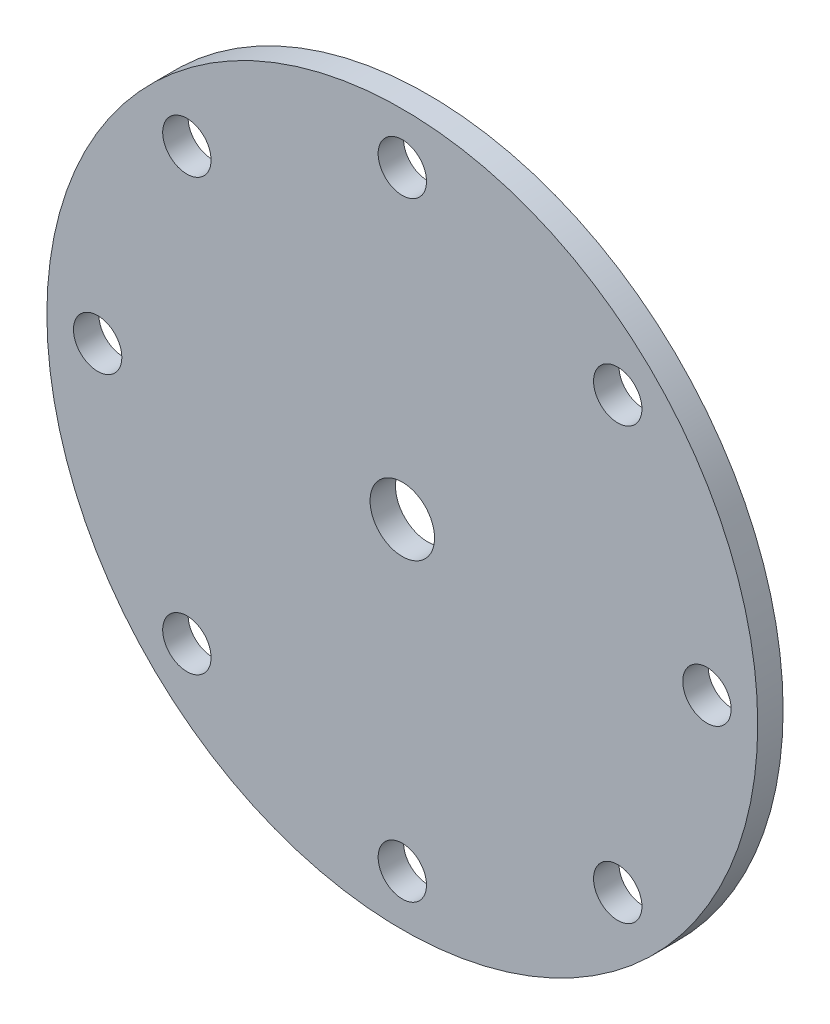
from build123d import *

# Parameters (mm, degrees)
SKETCH1_R        = 70
SKETCH1_R_2      = 6.35
SKETCH1_R_3      = 4.7625
ROTOR_DISC_DEPTH = 5


with BuildPart() as part:
    # Sketch1 → Rotor Disc (new body)
    with BuildSketch(Plane.XY):
        Circle(SKETCH1_R)
        Circle(SKETCH1_R_2, mode=Mode.SUBTRACT)
        with Locations((0, 60)):
            Circle(SKETCH1_R_3, mode=Mode.SUBTRACT)
        with Locations((42.426406871, 42.426406871)):
            Circle(SKETCH1_R_3, mode=Mode.SUBTRACT)
        with Locations((60, 0)):
            Circle(SKETCH1_R_3, mode=Mode.SUBTRACT)
        with Locations((42.426406871, -42.426406871)):
            Circle(SKETCH1_R_3, mode=Mode.SUBTRACT)
        with Locations((0, -60)):
            Circle(SKETCH1_R_3, mode=Mode.SUBTRACT)
        with Locations((-42.426406871, -42.426406871)):
            Circle(SKETCH1_R_3, mode=Mode.SUBTRACT)
        with Locations((-60, 0)):
            Circle(SKETCH1_R_3, mode=Mode.SUBTRACT)
        with Locations((-42.426406871, 42.426406871)):
            Circle(SKETCH1_R_3, mode=Mode.SUBTRACT)
    extrude(amount=ROTOR_DISC_DEPTH)


solid = part.part
